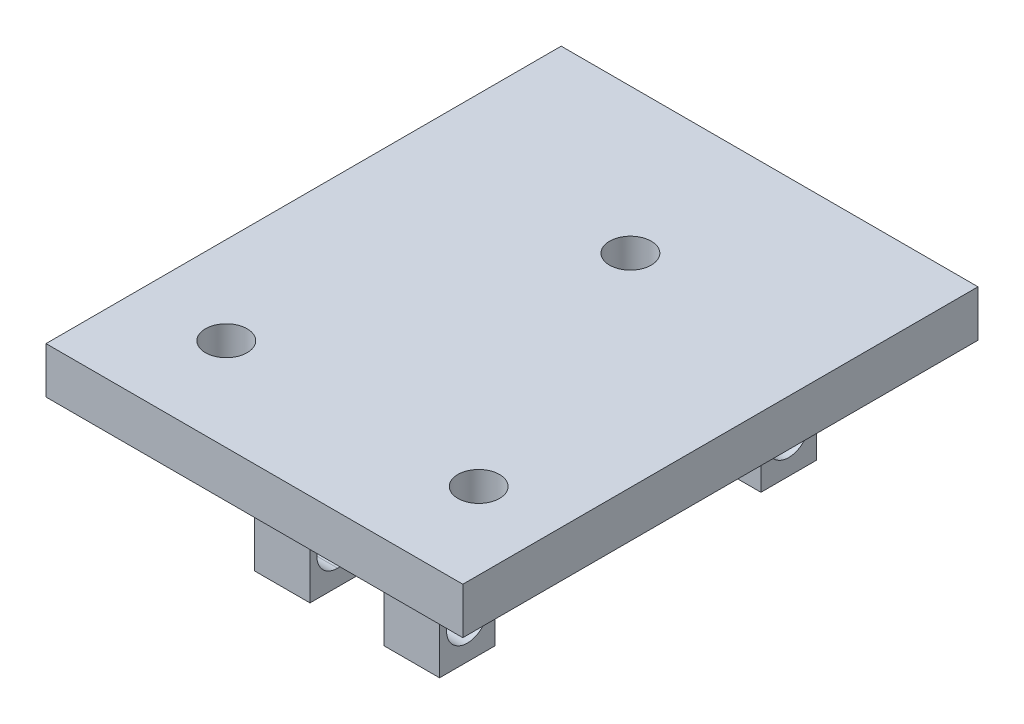
from build123d import *

# Parameters (mm, degrees)
BOSS_EXTRUDE1_DEPTH                 = 5
F_8_CLEARANCE_HOLE1_D               = 4.4958
F_8_CLEARANCE_HOLE1_DEPTH           = 17
F_8_CLEARANCE_HOLE1_TIP             = 1.350674586
SKETCH3_W                           = 6
SKETCH3_H                           = 6
BOSS_EXTRUDE2_DEPTH                 = 15
F_8_CLEARANCE_HOLE2_D               = 4.4958
F_8_CLEARANCE_HOLE2_DEPTH           = 17
F_8_CLEARANCE_HOLE2_TIP             = 1.350674586
F_8_CLEARANCE_HOLE2_ON_FACE_2_D     = 4.4958
F_8_CLEARANCE_HOLE2_ON_FACE_2_DEPTH = 17
F_8_CLEARANCE_HOLE2_ON_FACE_2_TIP   = 1.350674586


with BuildPart() as part:
    # Sketch1 → Boss-Extrude1 (new body)
    with BuildSketch(Plane(origin=(0, 0, 0), x_dir=(1, 0, 0), z_dir=(0, 1, 0))):
        Polygon((-14.338976611, 0), (30.661023389, 0), (30.661023389, 55.621488653), (8.161023389, 55.621488653), (-14.338976611, 55.621488653), align=None)
    extrude(amount=BOSS_EXTRUDE1_DEPTH)

    # #8 Clearance Hole1
    with Locations(Plane(origin=(22.377803879, 0, -10), x_dir=(0, 0, -1), z_dir=(0, -1, 0))):
        with Locations((0, 0), (0, -27.25), (30.001031232, -13.625)):
            Hole(F_8_CLEARANCE_HOLE1_D / 2, depth=F_8_CLEARANCE_HOLE1_DEPTH)
            with Locations((0, 0, -(F_8_CLEARANCE_HOLE1_DEPTH + F_8_CLEARANCE_HOLE1_TIP / 2))):  # 118° drill point
                Cone(0, F_8_CLEARANCE_HOLE1_D / 2, F_8_CLEARANCE_HOLE1_TIP, mode=Mode.SUBTRACT)

    # Sketch3 → Boss-Extrude2 (add)
    with BuildSketch(Plane(origin=(0, 0, 0), x_dir=(-1, 0, 0), z_dir=(0, -1, 0))):
        with Locations((-1.161023389, 47.5)):
            Rectangle(SKETCH3_W, SKETCH3_H)
        with Locations((-1.161023389, 13)):
            Rectangle(SKETCH3_W, SKETCH3_H)
        with Locations((-15.161023389, 47.684631069)):
            Rectangle(SKETCH3_W, SKETCH3_H)
        with Locations((-15.161023389, 12.990172473)):
            Rectangle(SKETCH3_W, SKETCH3_H)
    extrude(amount=BOSS_EXTRUDE2_DEPTH)

    # #8 Clearance Hole2
    with Locations(Plane(origin=(-1.838976611, -11, -47.5), x_dir=(0, 0, -1), z_dir=(-1, 0, 0))):
        with Locations((0, 0), (-34.5, 0)):
            Hole(F_8_CLEARANCE_HOLE2_D / 2, depth=F_8_CLEARANCE_HOLE2_DEPTH)
            with Locations((0, 0, -(F_8_CLEARANCE_HOLE2_DEPTH + F_8_CLEARANCE_HOLE2_TIP / 2))):  # 118° drill point
                Cone(0, F_8_CLEARANCE_HOLE2_D / 2, F_8_CLEARANCE_HOLE2_TIP, mode=Mode.SUBTRACT)

    # #8 Clearance Hole2 on face 2
    with Locations(Plane(origin=(18.161023389, -11, -47.684631069), x_dir=(0, 0, 1), z_dir=(1, 0, 0))):
        with Locations((0, 0), (34.694458596, 0)):
            Hole(F_8_CLEARANCE_HOLE2_ON_FACE_2_D / 2, depth=F_8_CLEARANCE_HOLE2_ON_FACE_2_DEPTH)
            with Locations((0, 0, -(F_8_CLEARANCE_HOLE2_ON_FACE_2_DEPTH + F_8_CLEARANCE_HOLE2_ON_FACE_2_TIP / 2))):  # 118° drill point
                Cone(0, F_8_CLEARANCE_HOLE2_ON_FACE_2_D / 2, F_8_CLEARANCE_HOLE2_ON_FACE_2_TIP, mode=Mode.SUBTRACT)


solid = part.part
